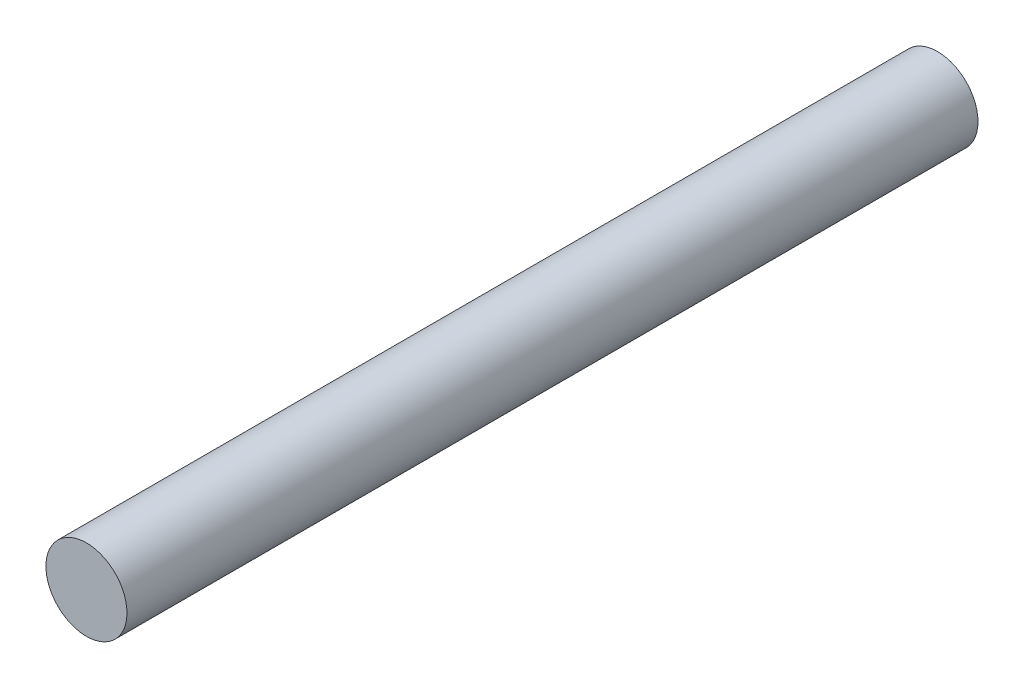
from build123d import *

# Parameters (mm, degrees)
SKETCH1_R           = 3
BOSS_EXTRUDE1_DEPTH = 63


with BuildPart() as part:
    # Sketch1 → Boss-Extrude1 (new body)
    with BuildSketch(Plane.XY):
        Circle(SKETCH1_R)
    extrude(amount=BOSS_EXTRUDE1_DEPTH)


solid = part.part
